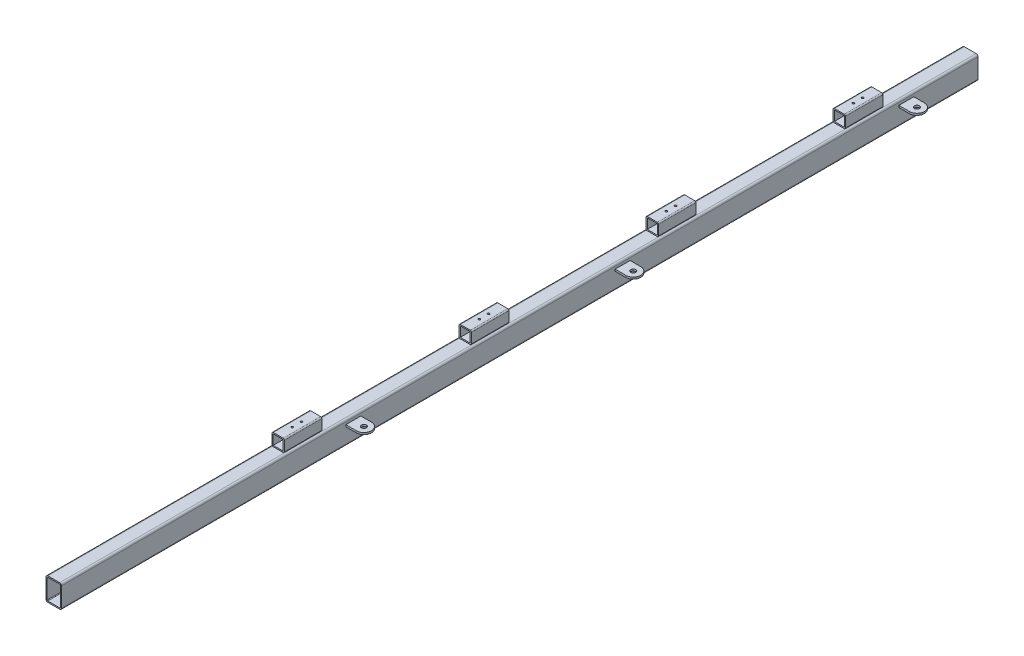
from build123d import *

# Parameters (mm, degrees)
EXTRUDE_THIN1_DEPTH  = 1470
SKETCH2_R            = 4
BOSS_EXTRUDE1_DEPTH  = 3
SKETCH3_W            = 16
SKETCH3_H            = 16
EXTRUDE_THIN2_DEPTH  = 60
M3_CLEARANCE_HOLE1_D = 3.2
LPATTERN1_COUNT      = 4
LPATTERN1_PITCH      = 300


with BuildPart() as part:
    # Sketch1 → Extrude-Thin1 (new body)
    with BuildSketch(Plane.XY):
        with BuildLine():
            Line((-9.5, 37), (9.5, 37))
            ThreePointArc((9.5, 37), (11.621320344, 36.121320344), (12.5, 34))
            Line((12.5, 34), (12.5, 3))
            ThreePointArc((12.5, 3), (11.621320344, 0.878679656), (9.5, 0))
            Line((9.5, 0), (-9.5, 0))
            ThreePointArc((-9.5, 0), (-11.621320344, 0.878679656), (-12.5, 3))
            Line((-12.5, 3), (-12.5, 34))
            ThreePointArc((-12.5, 34), (-11.621320344, 36.121320344), (-9.5, 37))
        make_face()
        with BuildLine():
            Line((-9.5, 35), (9.5, 35))
            ThreePointArc((9.5, 35), (10.207106781, 34.707106781), (10.5, 34))
            Line((10.5, 34), (10.5, 3))
            ThreePointArc((10.5, 3), (10.207106781, 2.292893219), (9.5, 2))
            Line((9.5, 2), (-9.5, 2))
            ThreePointArc((-9.5, 2), (-10.207106781, 2.292893219), (-10.5, 3))
            Line((-10.5, 3), (-10.5, 34))
            ThreePointArc((-10.5, 34), (-10.207106781, 34.707106781), (-9.5, 35))
        make_face(mode=Mode.SUBTRACT)
    extrude(amount=EXTRUDE_THIN1_DEPTH)

    # Sketch2 → Boss-Extrude1 (add)
    with BuildSketch(Plane(origin=(0, 27, 0), x_dir=(1, 0, 0), z_dir=(0, 1, 0))):
        with BuildLine():
            Line((29.5, -103), (12.5, -103))
            Line((12.5, -103), (12.5, -127))
            Line((12.5, -127), (29.5, -127))
            ThreePointArc((29.5, -127), (41.5, -115), (29.5, -103))
        make_face()
        with Locations((29.5, -115)):
            Circle(SKETCH2_R, mode=Mode.SUBTRACT)
        with BuildLine():
            Line((29.5, -558), (12.5, -558))
            Line((12.5, -558), (12.5, -582))
            Line((12.5, -582), (29.5, -582))
            ThreePointArc((29.5, -582), (41.5, -570), (29.5, -558))
        make_face()
        with Locations((29.5, -570)):
            Circle(SKETCH2_R, mode=Mode.SUBTRACT)
        with BuildLine():
            Line((29.5, -990), (12.5, -990))
            Line((12.5, -990), (12.5, -1014))
            Line((12.5, -1014), (29.5, -1014))
            ThreePointArc((29.5, -1014), (41.5, -1002), (29.5, -990))
        make_face()
        with Locations((29.5, -1002)):
            Circle(SKETCH2_R, mode=Mode.SUBTRACT)
    extrude(amount=BOSS_EXTRUDE1_DEPTH)

    # Sketch3 → Extrude-Thin2 (add)
    with BuildSketch(Plane(origin=(0, 0, 150), x_dir=(-1, 0, 0), z_dir=(0, 0, -1))):
        with BuildLine():
            Line((10, 55), (10, 39))
            ThreePointArc((10, 39), (9.414213562, 37.585786438), (8, 37))
            Line((8, 37), (-8, 37))
            ThreePointArc((-8, 37), (-9.414213562, 37.585786438), (-10, 39))
            Line((-10, 39), (-10, 55))
            ThreePointArc((-10, 55), (-9.414213562, 56.414213562), (-8, 57))
            Line((-8, 57), (8, 57))
            ThreePointArc((8, 57), (9.414213562, 56.414213562), (10, 55))
        make_face()
        with Locations((0, 47)):
            Rectangle(SKETCH3_W, SKETCH3_H, mode=Mode.SUBTRACT)
    extrude_thin2 = extrude(amount=-EXTRUDE_THIN2_DEPTH)

    # M3 Clearance Hole1 (through all)
    with Locations(Plane(origin=(0, 57, 0), x_dir=(1, 0, 0), z_dir=(0, 1, 0))):
        with Locations((0, -187.45), (0, -172.55)):
            m3_clearance_hole1 = Hole(M3_CLEARANCE_HOLE1_D / 2)

    # LPattern1: Extrude-Thin2, M3 Clearance Hole1 ×4
    with Locations(*[(0, 0, i * LPATTERN1_PITCH) for i in range(1, LPATTERN1_COUNT)]):
        add(extrude_thin2)
        add(m3_clearance_hole1, mode=Mode.SUBTRACT)


solid = part.part
